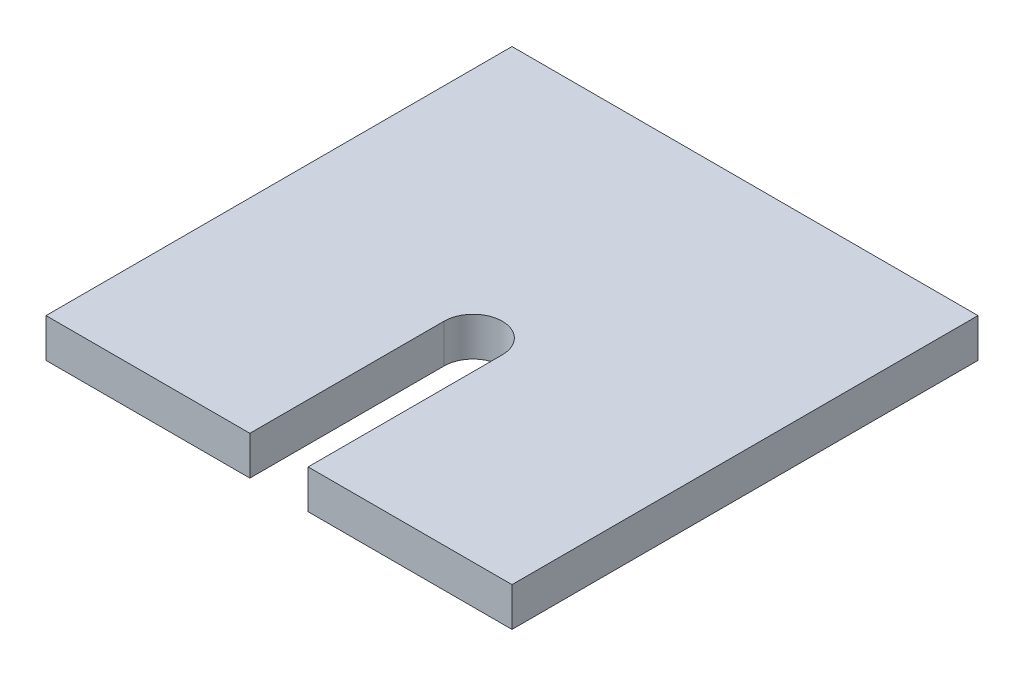
from build123d import *

# Parameters (mm, degrees)
BOSS_EXTRUDE1_DEPTH = 6.35


with BuildPart() as part:
    # Sketch9 → Boss-Extrude1 (new body)
    with BuildSketch(Plane(origin=(0, 0, 0), x_dir=(1, 0, 0), z_dir=(0, 1, 0))):
        with BuildLine():
            Line((-30.309488668, -47.754689913), (3.028011332, -47.754689913))
            Line((3.028011332, -47.754689913), (3.028011332, 28.445310087))
            Line((3.028011332, 28.445310087), (-73.171988668, 28.445310087))
            Line((-73.171988668, 28.445310087), (-73.171988668, -47.754689913))
            Line((-73.171988668, -47.754689913), (-39.834488668, -47.754689913))
            Line((-39.834488668, -47.754689913), (-39.834488668, -16.004689913))
            ThreePointArc((-39.834488668, -16.004689913), (-35.071988668, -11.242189913), (-30.309488668, -16.004689913))
            Line((-30.309488668, -16.004689913), (-30.309488668, -47.754689913))
        make_face()
    extrude(amount=BOSS_EXTRUDE1_DEPTH)


solid = part.part
